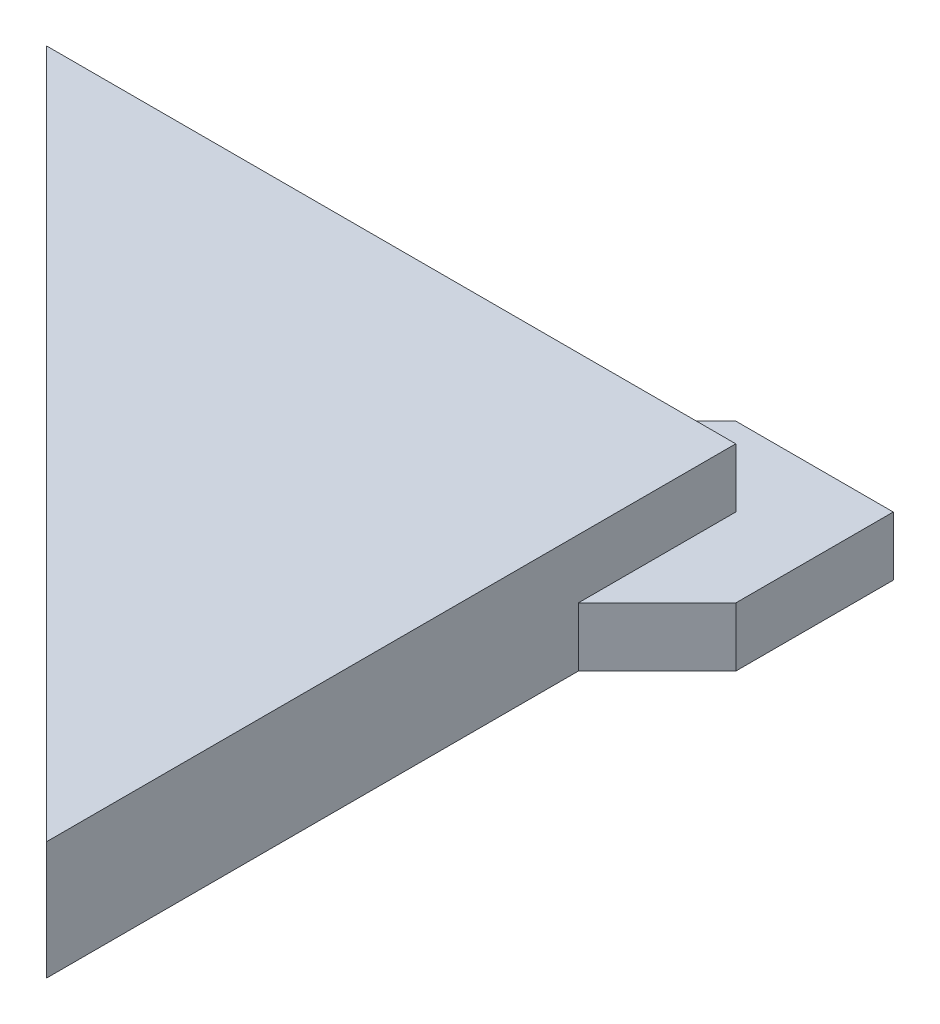
from build123d import *

# Parameters (mm, degrees)
BOSS_EXTRUDE1_DEPTH = 6
BOSS_EXTRUDE2_DEPTH = 3


with BuildPart() as part:
    # Sketch1 → Boss-Extrude1 (new body)
    with BuildSketch(Plane(origin=(0, 0, 0), x_dir=(1, 0, 0), z_dir=(0, 1, 0))):
        Polygon((-35, 35), (0, 0), (0, 27), (0, 35), (-8, 35), align=None)
    extrude(amount=BOSS_EXTRUDE1_DEPTH)

    # Sketch1_3 → Boss-Extrude2 (add)
    with BuildSketch(Plane(origin=(0, 0, 0), x_dir=(1, 0, 0), z_dir=(0, 1, 0))):
        Polygon((0, 35), (0, 27), (4, 31), (4, 39), (-4, 39), (-8, 35), align=None)
    extrude(amount=BOSS_EXTRUDE2_DEPTH)


solid = part.part
